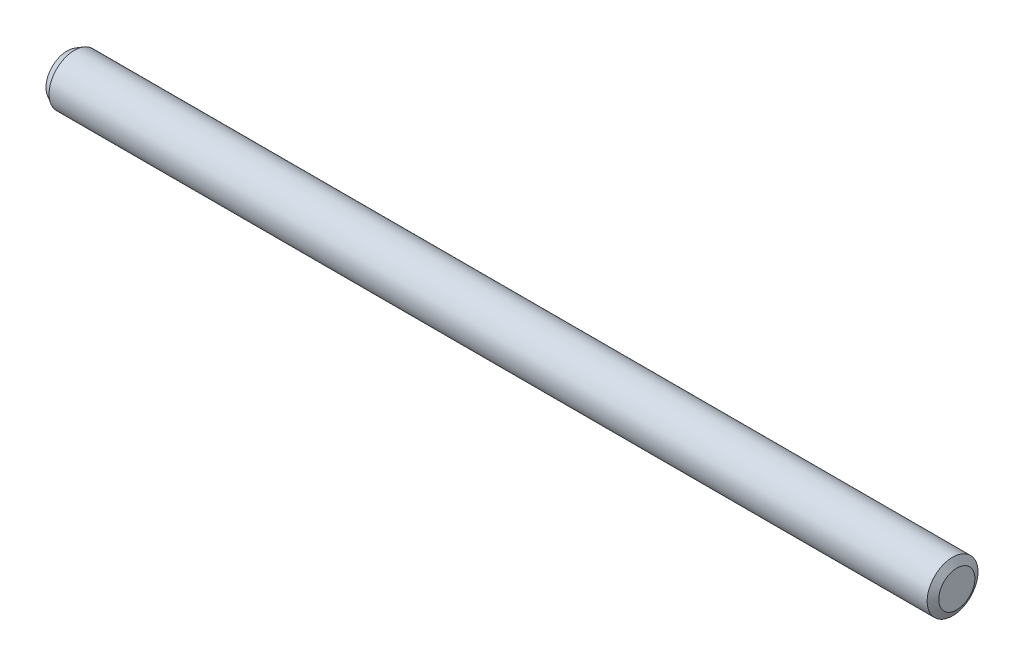
from build123d import *

# Parameters (mm, degrees)
SKETCH1_R             = 3
BOSS_EXTRUDE1_DEPTH   = 52.5
CHAMFER1_SIZE         = 0.5
CHAMFER1_SIZE2        = 0.866025404
CHAMFER1_PART_2_SIZE  = 0.5
CHAMFER1_PART_2_SIZE2 = 0.866025404


with BuildPart() as part:
    # Sketch1 → Boss-Extrude1 (new body, symmetric)
    with BuildSketch(Plane(origin=(0, 0, 0), x_dir=(0, 0, -1), z_dir=(1, 0, 0))):
        Circle(SKETCH1_R)
    extrude(amount=BOSS_EXTRUDE1_DEPTH, both=True)

    # Chamfer1
    chamfer1_edges = [part.edges().sort_by_distance(p)[0] for p in [
        (-52.5, 0, 3),
    ]]
    chamfer1_side = [part.faces().sort_by_distance(p)[0] for p in [
        (-52.5, 0, 0),
    ]]
    chamfer(chamfer1_edges, length=CHAMFER1_SIZE, length2=CHAMFER1_SIZE2, reference=chamfer1_side[0])

    # Chamfer1 part 2
    chamfer1_part_2_edges = [part.edges().sort_by_distance(p)[0] for p in [
        (52.5, 0, 3),
    ]]
    chamfer1_part_2_side = [part.faces().sort_by_distance(p)[0] for p in [
        (0, 0, 3),
    ]]
    chamfer(chamfer1_part_2_edges, length=CHAMFER1_PART_2_SIZE, length2=CHAMFER1_PART_2_SIZE2, reference=chamfer1_part_2_side[0])


solid = part.part
